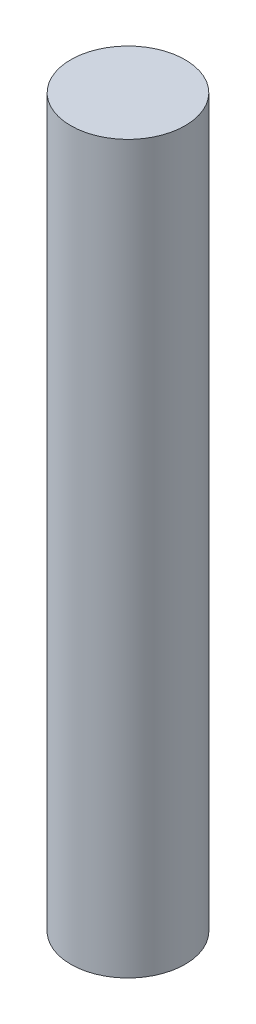
from build123d import *

# Parameters (mm, degrees)
SKETCH1_R           = 2.5
BOSS_EXTRUDE1_DEPTH = 15.875


with BuildPart() as part:
    # Sketch1 → Boss-Extrude1 (new body, symmetric)
    with BuildSketch(Plane(origin=(0, 0, 0), x_dir=(1, 0, 0), z_dir=(0, 1, 0))):
        Circle(SKETCH1_R)
    extrude(amount=BOSS_EXTRUDE1_DEPTH, both=True)


solid = part.part
